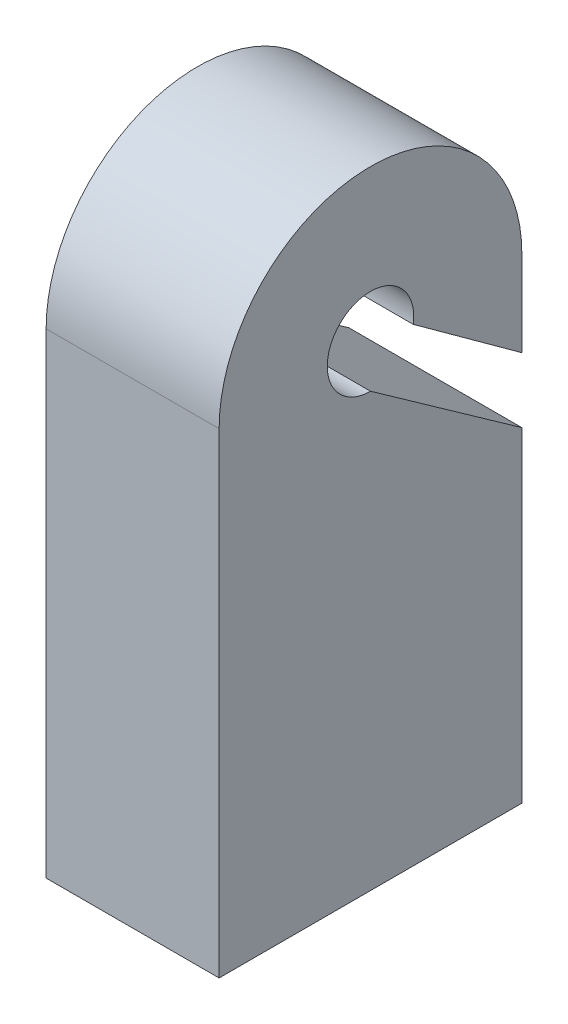
from build123d import *

# Parameters (mm, degrees)
BOSS_EXTRUDE1_DEPTH = 2


with BuildPart() as part:
    # Sketch1 → Boss-Extrude1 (new body)
    with BuildSketch(Plane(origin=(0, 0, 0), x_dir=(0, 0, -1), z_dir=(1, 0, 0))):
        with BuildLine():
            Line((-2, -2.5), (1.5, -2.5))
            Line((1.5, -2.5), (1.5, 0.193510405))
            Line((1.5, 0.193510405), (1.5, 0.544384676))
            Line((1.5, 0.544384676), (1.5, 1.260642871))
            Line((1.5, 1.260642871), (-0.25, 2.5))
            ThreePointArc((-0.25, 2.5), (-0.575, 3.379967104), (0.243957235, 2.9225))
            Line((0.243957235, 2.9225), (1.5, 2.010642871))
            Line((1.5, 2.010642871), (1.5, 3))
            ThreePointArc((1.5, 3), (-0.25, 4.75), (-2, 3))
            Line((-2, 3), (-2, -2.5))
        make_face()
    extrude(amount=BOSS_EXTRUDE1_DEPTH)


solid = part.part
